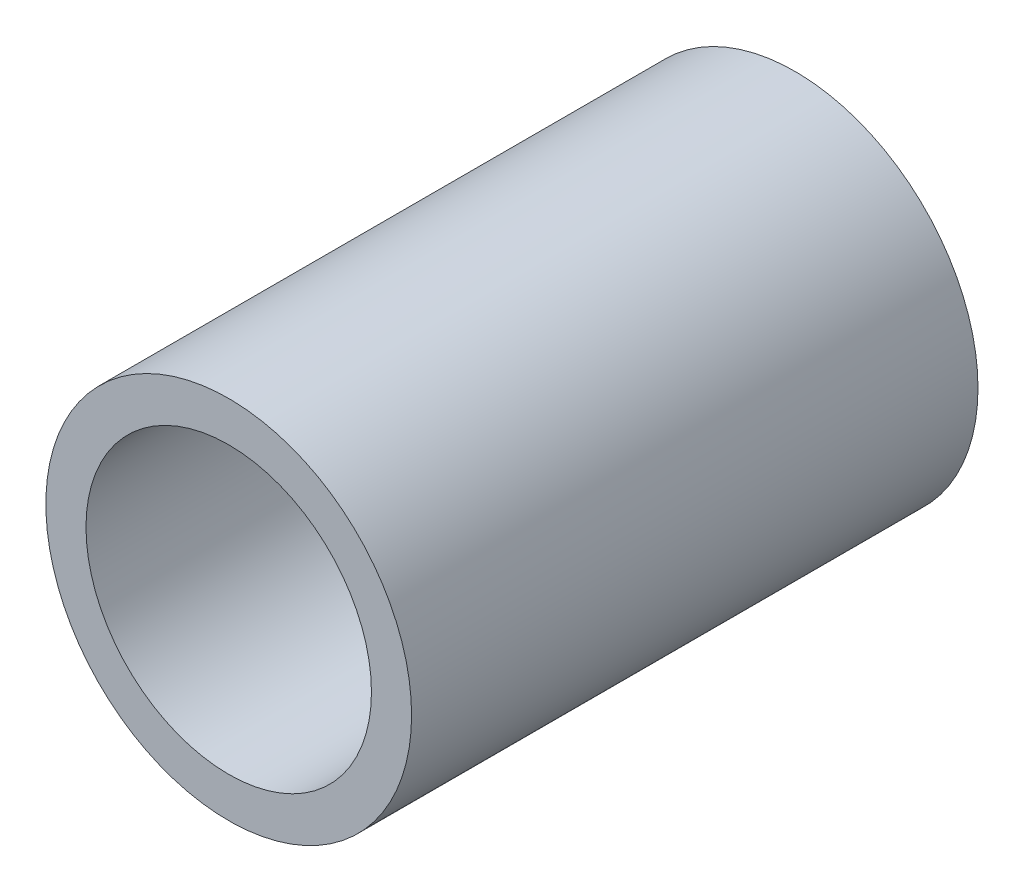
from build123d import *

# Parameters (mm, degrees)
SKETCH1_W = 22.225
SKETCH1_H = 1.5748


with BuildPart() as part:
    # Sketch1 → Revolve1 (revolve)
    with BuildSketch(Plane(origin=(0, 0, 0), x_dir=(0, 0, -1), z_dir=(1, 0, 0))):
        with Locations((0, 6.3881)):
            Rectangle(SKETCH1_W, SKETCH1_H)
    revolve(axis=Axis((0, 0, -11.1125), (0, 0, 1)))


solid = part.part
